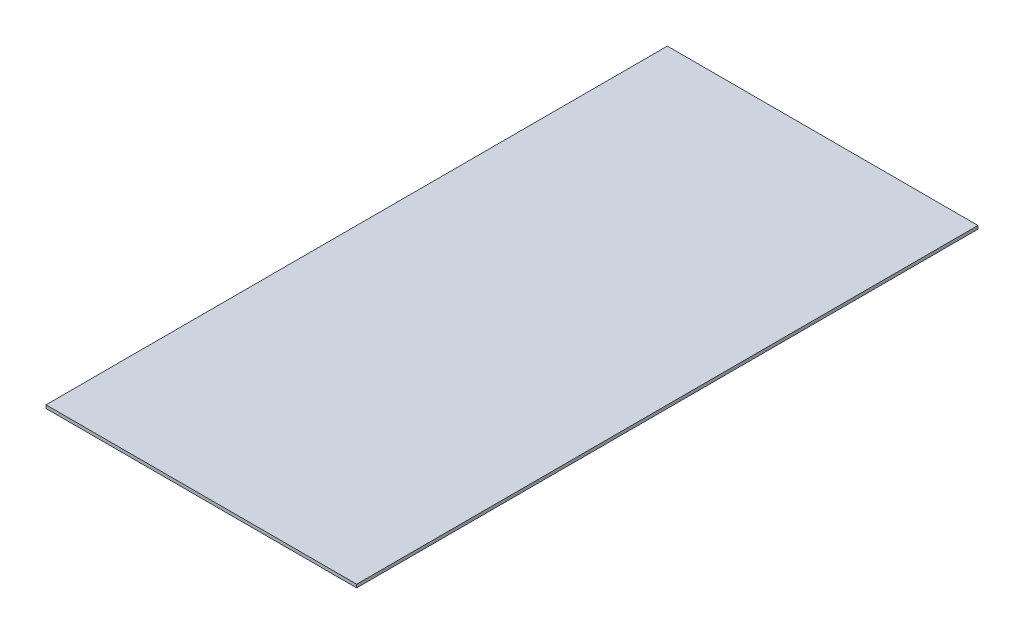
from build123d import *

# Parameters (mm, degrees)
SKETCH2_W           = 304.8
SKETCH2_H           = 609.6
BOSS_EXTRUDE1_DEPTH = 3.175


with BuildPart() as part:
    # Sketch2 → Boss-Extrude1 (new body)
    with BuildSketch(Plane(origin=(0, 0, 0), x_dir=(1, 0, 0), z_dir=(0, 1, 0))):
        Rectangle(SKETCH2_W, SKETCH2_H)
    extrude(amount=BOSS_EXTRUDE1_DEPTH)


solid = part.part
